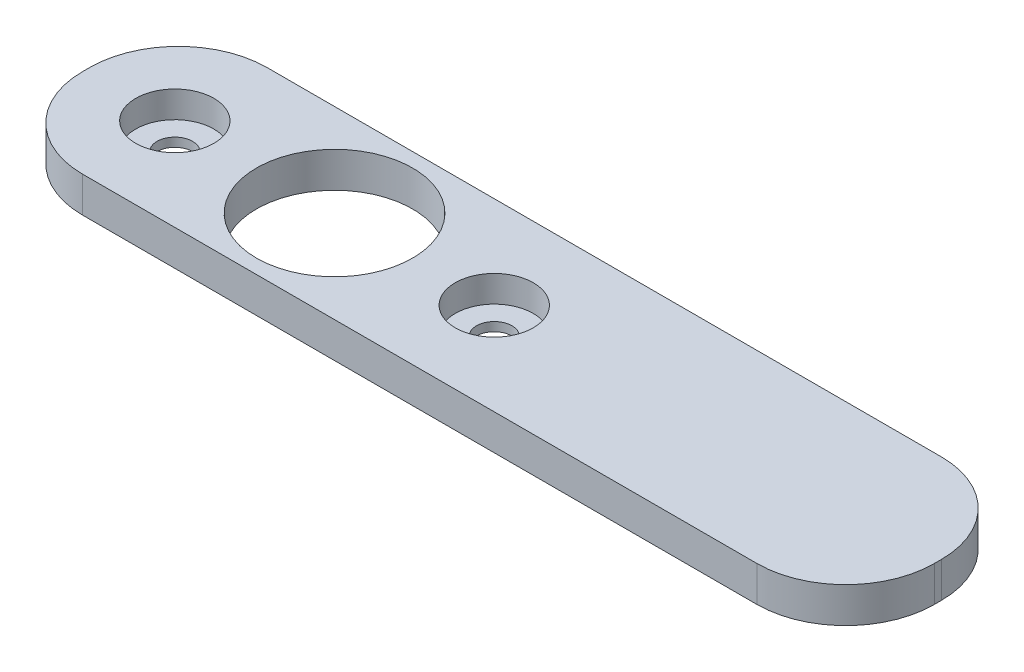
from build123d import *

# Parameters (mm, degrees)
SKETCH1_R           = 11
SKETCH1_R_2         = 22
BOSS_EXTRUDE1_DEPTH = 10
BOSS_EXTRUDE4_DEPTH = 10
CUT_EXTRUDE1_DEPTH  = 10
BOSS_EXTRUDE5_DEPTH = 10
BOSS_EXTRUDE6_DEPTH = 10
SKETCH2_R           = 12.791308891
SKETCH2_R_2         = 5
SKETCH2_R_3         = 12.648974484
BOSS_EXTRUDE2_DEPTH = 2.5
CUT_EXTRUDE2_DEPTH  = 10
FILLET1_R           = 25
BOSS_EXTRUDE7_DEPTH = 10
FILLET2_R           = 25
FILLET3_R           = 25
CUT_EXTRUDE5_DEPTH  = 10
BOSS_EXTRUDE8_DEPTH = 10
BOSS_EXTRUDE9_DEPTH = 10
FILLET4_R           = 25


with BuildPart() as part:
    # Sketch1 → Boss-Extrude1 (new body)
    with BuildSketch(Plane(origin=(0, 0, 0), x_dir=(1, 0, 0), z_dir=(0, 1, 0))):
        with BuildLine():
            Line((-70, -27), (-25, -27))
            Line((-25, -27), (25, -27))
            Line((25, -27), (70, -27))
            Line((70, -27), (70, 0))
            ThreePointArc((70, 0), (62.67766953, 17.67766953), (45, 25))
            Line((45, 25), (-45, 25))
            ThreePointArc((-45, 25), (-62.67766953, 17.67766953), (-70, 0))
            Line((-70, 0), (-70, -27))
        make_face()
        with Locations(Location((-45, 0, 0), (0, 0, 90))):  # turned: the seam where the file's is
            Circle(SKETCH1_R, mode=Mode.SUBTRACT)
        with Locations(Location((0, 0, 0), (0, 0, 270))):  # turned: the seam where the file's is
            Circle(SKETCH1_R_2, mode=Mode.SUBTRACT)
        with Locations(Location((45, 0, 0), (0, 0, 270))):  # turned: the seam where the file's is
            Circle(SKETCH1_R, mode=Mode.SUBTRACT)
    extrude(amount=BOSS_EXTRUDE1_DEPTH)

    # Sketch3_2 → Boss-Extrude4 (add)
    with BuildSketch(Plane(origin=(0, 10, 0), x_dir=(1, 0, 0), z_dir=(0, 1, 0))):
        Polygon((-70, -27), (-121.413521395, -27), (-121.413521395, 25), (-45, 25), (-60.069243324, 8.259929081), align=None)
    extrude(amount=-BOSS_EXTRUDE4_DEPTH)

    # Sketch3 → Cut-Extrude1 (cut)
    with BuildSketch(Plane(origin=(0, 10, 0), x_dir=(1, 0, 0), z_dir=(0, 1, 0))):
        Polygon((-70, -27), (-121.413521395, -27), (-121.413521395, 25), (-45, 25), (-60.069243324, 8.259929081), align=None)
    extrude(amount=-CUT_EXTRUDE1_DEPTH, mode=Mode.SUBTRACT)

    # Sketch5 → Boss-Extrude5 (add)
    with BuildSketch(Plane(origin=(0, 10, 0), x_dir=(1, 0, 0), z_dir=(0, 1, 0))):
        Polygon((-70, -27), (-152.396081637, -27), (-152.396081637, 25), (-45, 25), (-47.056495807, 18.199026423), (-57.650043642, 5.920141433), (-62.706055109, -17.674578746), align=None)
    extrude(amount=-BOSS_EXTRUDE5_DEPTH)

    # Sketch6 → Boss-Extrude6 (add)
    with BuildSketch(Plane(origin=(0, 10, 0), x_dir=(1, 0, 0), z_dir=(0, 1, 0))):
        Polygon((-170, -27), (-147.259885351, -27), (-136.049250897, -7.734745997), (-143.609911342, 12.600823478), (-152.396081637, 25), (-170, 25), align=None)
    extrude(amount=-BOSS_EXTRUDE6_DEPTH)

    # Sketch2 → Boss-Extrude2 (add)
    with BuildSketch(Plane.XZ):
        with Locations((-45, 0)):
            Circle(SKETCH2_R)
        with Locations(Location((-45, 0, 0), (0, 0, 270))):  # turned: the seam where the file's is
            Circle(SKETCH2_R_2, mode=Mode.SUBTRACT)
        with Locations((45, 0)):
            Circle(SKETCH2_R_3)
        with Locations(Location((45, 0, 0), (0, 0, 270))):  # turned: the seam where the file's is
            Circle(SKETCH2_R_2, mode=Mode.SUBTRACT)
    extrude(amount=-BOSS_EXTRUDE2_DEPTH)

    # Sketch7 → Cut-Extrude2 (cut)
    with BuildSketch(Plane(origin=(0, 10, 0), x_dir=(1, 0, 0), z_dir=(0, 1, 0))):
        Polygon((-70, -27), (-70, 25), (-80.950376598, 84.263900648), (-214.684311222, 75.641343309), (-217.522149123, -21.969417176), (-150.276663253, -84.577260073), align=None)
    extrude(amount=-CUT_EXTRUDE2_DEPTH, mode=Mode.SUBTRACT)

    # Fillet1
    fillet1_edges = [part.edges().sort_by_distance(p)[0] for p in [
        (-70, 5, -25),
    ]]
    fillet(fillet1_edges, radius=FILLET1_R)

    # Sketch8 → Boss-Extrude7 (add)
    with BuildSketch(Plane(origin=(0, 10, 0), x_dir=(1, 0, 0), z_dir=(0, 1, 0))):
        Polygon((45, 25), (170, 25), (170, -27), (70, -27), (59.971259961, 0), align=None)
    extrude(amount=-BOSS_EXTRUDE7_DEPTH)

    # Fillet2
    fillet2_edges = [part.edges().sort_by_distance(p)[0] for p in [
        (170, 5, -25),
    ]]
    fillet(fillet2_edges, radius=FILLET2_R)

    # Fillet3
    fillet3_edges = [part.edges().sort_by_distance(p)[0] for p in [
        (-70, 5, 27),
        (170, 5, 27),
    ]]
    fillet(fillet3_edges, radius=FILLET3_R)

    # Sketch9 → Cut-Extrude5 (cut)
    with BuildSketch(Plane(origin=(0, 10, 0), x_dir=(1, 0, 0), z_dir=(0, 1, 0))):
        with BuildLine():
            Line((168.265391903, -53.084180291), (170, -26))
            Line((170, -26), (152, -26))
            ThreePointArc((152, -26), (148.535533906, -26.748737342), (145, -27))
            Line((145, -27), (-45, -27))
            ThreePointArc((-45, -27), (-48.535533906, -26.748737342), (-52, -26))
            Line((-52, -26), (-70, -26))
            Line((-70, -26), (-6.059888958, -84.123320181))
            Line((-6.059888958, -84.123320181), (168.265391903, -53.084180291))
        make_face()
        with BuildLine():
            ThreePointArc((145, -27), (148.535533906, -26.748737342), (152, -26))
            Line((152, -26), (-52, -26))
            ThreePointArc((-52, -26), (-48.535533906, -26.748737342), (-45, -27))
            Line((-45, -27), (145, -27))
        make_face()
    extrude(amount=-CUT_EXTRUDE5_DEPTH, mode=Mode.SUBTRACT)

    # Sketch10 → Boss-Extrude8 (add)
    with BuildSketch(Plane(origin=(0, 10, 0), x_dir=(1, 0, 0), z_dir=(0, 1, 0))):
        with BuildLine():
            Line((-14.39135104, -23.974647324), (-57.930920378, -15.319190769))
            Line((-57.930920378, -15.319190769), (-70, 0))
            Line((-70, 0), (-70, -2))
            ThreePointArc((-70, -2), (-65, -17), (-52, -26))
            Line((-52, -26), (152, -26))
            ThreePointArc((152, -26), (165, -17), (170, -2))
            Line((170, -2), (170, 0))
            Line((170, 0), (125.93195978, -21.351781701))
            Line((125.93195978, -21.351781701), (-14.39135104, -23.974647324))
        make_face()
        with BuildLine():
            Line((170, -26), (170, -2))
            ThreePointArc((170, -2), (165, -17), (152, -26))
            Line((152, -26), (170, -26))
        make_face()
        with BuildLine():
            ThreePointArc((-52, -26), (-65, -17), (-70, -2))
            Line((-70, -2), (-70, -26))
            Line((-70, -26), (-52, -26))
        make_face()
    extrude(amount=-BOSS_EXTRUDE8_DEPTH)

    # Sketch11 → Boss-Extrude9 (add)
    with BuildSketch(Plane(origin=(0, 10, 0), x_dir=(1, 0, 0), z_dir=(0, 1, 0))):
        with BuildLine():
            Line((-57.382853391, 13.015294561), (-70, 0))
            ThreePointArc((-70, 0), (-62.67766953, 17.67766953), (-45, 25))
            Line((-45, 25), (145, 25))
            ThreePointArc((145, 25), (162.67766953, 17.67766953), (170, 0))
            Line((170, 0), (115.178210727, 18.515775765))
            Line((115.178210727, 18.515775765), (14.984743936, 21.925501075))
            Line((14.984743936, 21.925501075), (-3.225773035, 23.26883074))
            Line((-3.225773035, 23.26883074), (-31.681488845, 16.787813616))
            Line((-31.681488845, 16.787813616), (-57.382853391, 13.015294561))
        make_face()
        with BuildLine():
            Line((170, 0), (170, 26))
            Line((170, 26), (-70, 26))
            Line((-70, 26), (-70, 0))
            ThreePointArc((-70, 0), (-62.67766953, 17.67766953), (-45, 25))
            Line((-45, 25), (145, 25))
            ThreePointArc((145, 25), (162.67766953, 17.67766953), (170, 0))
        make_face()
    extrude(amount=-BOSS_EXTRUDE9_DEPTH)

    # Fillet4
    fillet4_edges = [part.edges().sort_by_distance(p)[0] for p in [
        (170, 5, 26),
        (-70, 5, 26),
        (-70, 5, -26),
        (170, 5, -26),
    ]]
    fillet(fillet4_edges, radius=FILLET4_R)


solid = part.part
